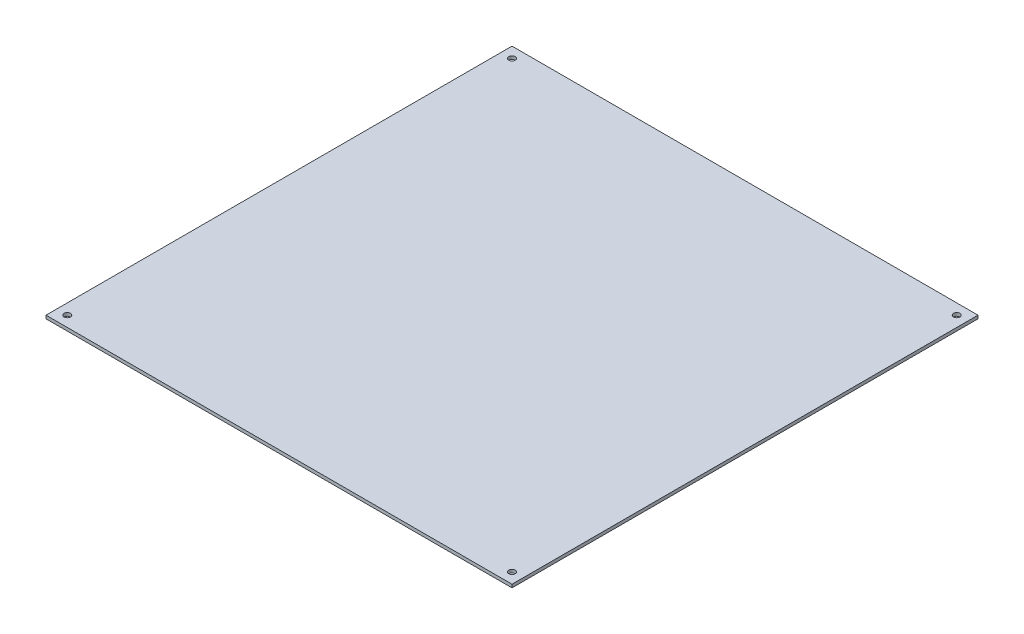
from build123d import *

# Parameters (mm, degrees)
SKETCH1_W           = 219
SKETCH1_H           = 219
SKETCH1_R           = 1.5
BOSS_EXTRUDE1_DEPTH = 1.5


with BuildPart() as part:
    # Sketch1 → Boss-Extrude1 (new body)
    with BuildSketch(Plane(origin=(0, 0, 0), x_dir=(1, 0, 0), z_dir=(0, 1, 0))):
        with Locations((-109.5, 109.5)):
            Rectangle(SKETCH1_W, SKETCH1_H)
        with Locations((-214, 214)):
            Circle(SKETCH1_R, mode=Mode.SUBTRACT)
        with Locations((-214, 5)):
            Circle(SKETCH1_R, mode=Mode.SUBTRACT)
        with Locations((-5, 5)):
            Circle(SKETCH1_R, mode=Mode.SUBTRACT)
        with Locations((-5, 214)):
            Circle(SKETCH1_R, mode=Mode.SUBTRACT)
    extrude(amount=BOSS_EXTRUDE1_DEPTH)


solid = part.part
